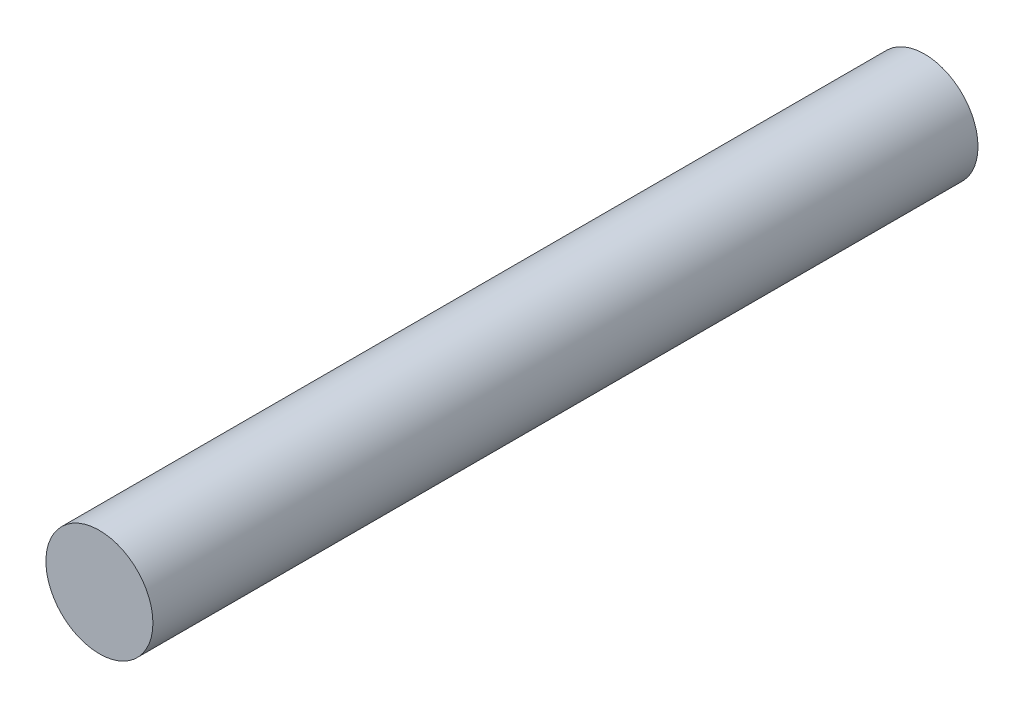
from build123d import *

# Parameters (mm, degrees)
SKETCH1_R           = 2.8
BOSS_EXTRUDE1_DEPTH = 43.18


with BuildPart() as part:
    # Sketch1 → Boss-Extrude1 (new body)
    with BuildSketch(Plane.XY):
        Circle(SKETCH1_R)
    extrude(amount=BOSS_EXTRUDE1_DEPTH)


solid = part.part
